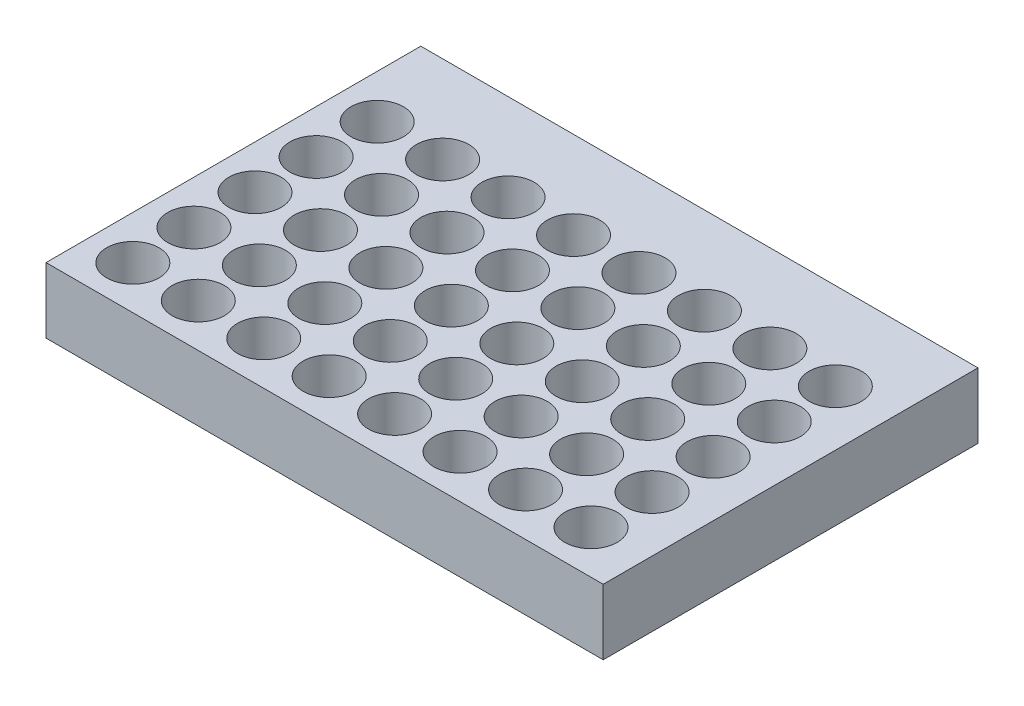
from build123d import *

# Parameters (mm, degrees)
SKETCH1_W            = 127.7
SKETCH1_H            = 85.9
BOSS_EXTRUDE1_DEPTH  = 15
SKETCH2_R            = 6
CUT_EXTRUDE1_DEPTH   = 12
LPATTERN3_COUNT      = 8
LPATTERN3_PITCH      = 15
LPATTERN3_COUNT_DIR2 = 5
LPATTERN3_PITCH_DIR2 = 14
SKETCH3_R            = 2
CUT_EXTRUDE2_DEPTH   = 12
LPATTERN4_COUNT      = 8
LPATTERN4_PITCH      = 15
LPATTERN4_COUNT_DIR2 = 5
LPATTERN4_PITCH_DIR2 = 14


with BuildPart() as part:
    # Sketch1 → Boss-Extrude1 (new body)
    with BuildSketch(Plane(origin=(0, 0, 0), x_dir=(1, 0, 0), z_dir=(0, 1, 0))):
        with Locations((-248.856003869, 89.066665881)):
            Rectangle(SKETCH1_W, SKETCH1_H)
    extrude(amount=BOSS_EXTRUDE1_DEPTH)

    # Sketch2 → Cut-Extrude1 (cut)
    with BuildSketch(Plane(origin=(0, 15, 0), x_dir=(1, 0, 0), z_dir=(0, 1, 0))):
        with Locations((-302.706003869, 112.016665881)):
            Circle(SKETCH2_R)
    cut_extrude1 = extrude(amount=-CUT_EXTRUDE1_DEPTH, mode=Mode.SUBTRACT)

    # LPattern3: Cut-Extrude1 8 × 5
    with Locations(*[(i * LPATTERN3_PITCH, 0, j * LPATTERN3_PITCH_DIR2) for i in range(LPATTERN3_COUNT) for j in range(LPATTERN3_COUNT_DIR2) if (i, j) != (0, 0)]):
        add(cut_extrude1, mode=Mode.SUBTRACT)

    # Sketch3 → Cut-Extrude2 (cut)
    with BuildSketch(Plane(origin=(0, 3, 0), x_dir=(1, 0, 0), z_dir=(0, 1, 0))):
        with Locations((-302.706003869, 112.016665881)):
            Circle(SKETCH3_R)
    cut_extrude2 = extrude(amount=-CUT_EXTRUDE2_DEPTH, mode=Mode.SUBTRACT)

    # LPattern4: Cut-Extrude2 8 × 5
    with Locations(*[(i * LPATTERN4_PITCH, 0, j * LPATTERN4_PITCH_DIR2) for i in range(LPATTERN4_COUNT) for j in range(LPATTERN4_COUNT_DIR2) if (i, j) != (0, 0)]):
        add(cut_extrude2, mode=Mode.SUBTRACT)


solid = part.part
